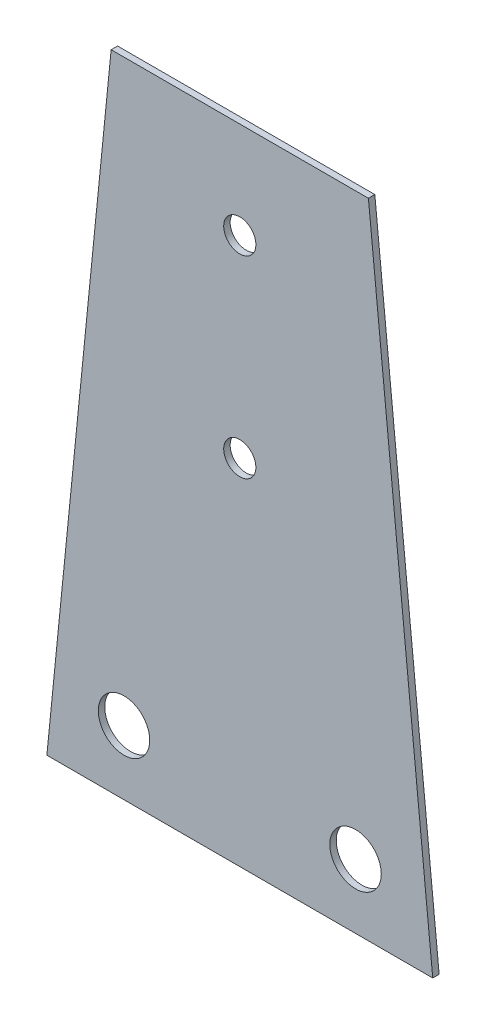
from build123d import *

# Parameters (mm, degrees)
BOSS_EXTRUDE1_DEPTH = 1
SKETCH3_R           = 4
SKETCH3_R_2         = 2.5
CUT_EXTRUDE1_DEPTH  = 2


with BuildPart() as part:
    # Sketch2 → Boss-Extrude1 (new body)
    with BuildSketch(Plane.XY):
        Polygon((-20, 75.180318298), (20, 75.180318298), (30, -24.819681702), (-30, -24.819681702), align=None)
    extrude(amount=BOSS_EXTRUDE1_DEPTH)

    # Sketch3 → Cut-Extrude1 (cut, through all)
    with BuildSketch(Plane.XY.offset(1)):
        with Locations((18, -14.819681702)):
            Circle(SKETCH3_R)
        with Locations((-18, -14.819681702)):
            Circle(SKETCH3_R)
        with Locations((0, 60.180318298)):
            Circle(SKETCH3_R_2)
        with Locations((0, 30.180318298)):
            Circle(SKETCH3_R_2)
    extrude(amount=-CUT_EXTRUDE1_DEPTH, mode=Mode.SUBTRACT)


solid = part.part
